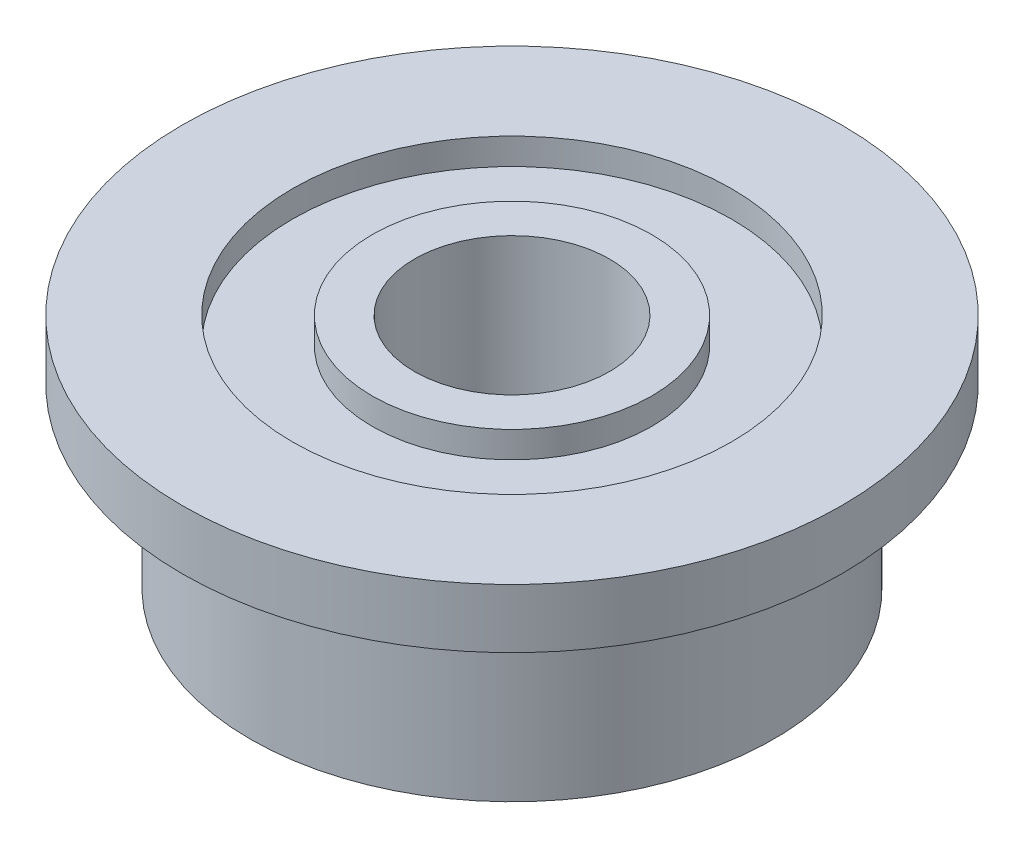
from build123d import *


with BuildPart() as part:
    # Sketch1 → Revolve1 (revolve)
    with BuildSketch(Plane.XY):
        Polygon((3.125, 0), (2.08, 0), (2.08, -0.25), (1.325, -0.25), (1.325, 0), (0.925, 0), (0.925, -2.24), (1.325, -2.24), (1.325, -1.99), (2.08, -1.99), (2.08, -2.24), (2.48, -2.24), (2.48, -0.56), (3.125, -0.56), align=None)
    revolve(axis=Axis((0, 0, 0), (0, -1, 0)))


solid = part.part
